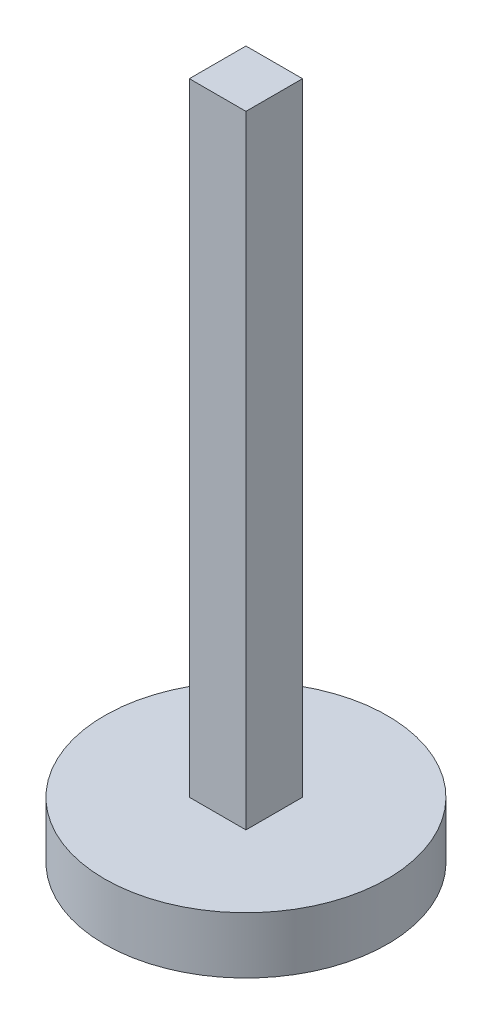
from build123d import *

# Parameters (mm, degrees)
SKETCH1_R           = 50
SKETCH1_W           = 20
SKETCH1_H           = 20
BOSS_EXTRUDE1_DEPTH = 20
SKETCH1_2_W         = 20
SKETCH1_2_H         = 20
BOSS_EXTRUDE2_DEPTH = 240


with BuildPart() as part:
    # Sketch1 → Boss-Extrude1 (new body)
    with BuildSketch(Plane(origin=(0, 0, 0), x_dir=(1, 0, 0), z_dir=(0, 1, 0))):
        Circle(SKETCH1_R)
        Rectangle(SKETCH1_W, SKETCH1_H, mode=Mode.SUBTRACT)
    extrude(amount=BOSS_EXTRUDE1_DEPTH)

    # Sketch1_2 → Boss-Extrude2 (add)
    with BuildSketch(Plane(origin=(0, 0, 0), x_dir=(1, 0, 0), z_dir=(0, 1, 0))):
        Rectangle(SKETCH1_2_W, SKETCH1_2_H)
    extrude(amount=BOSS_EXTRUDE2_DEPTH)


solid = part.part
